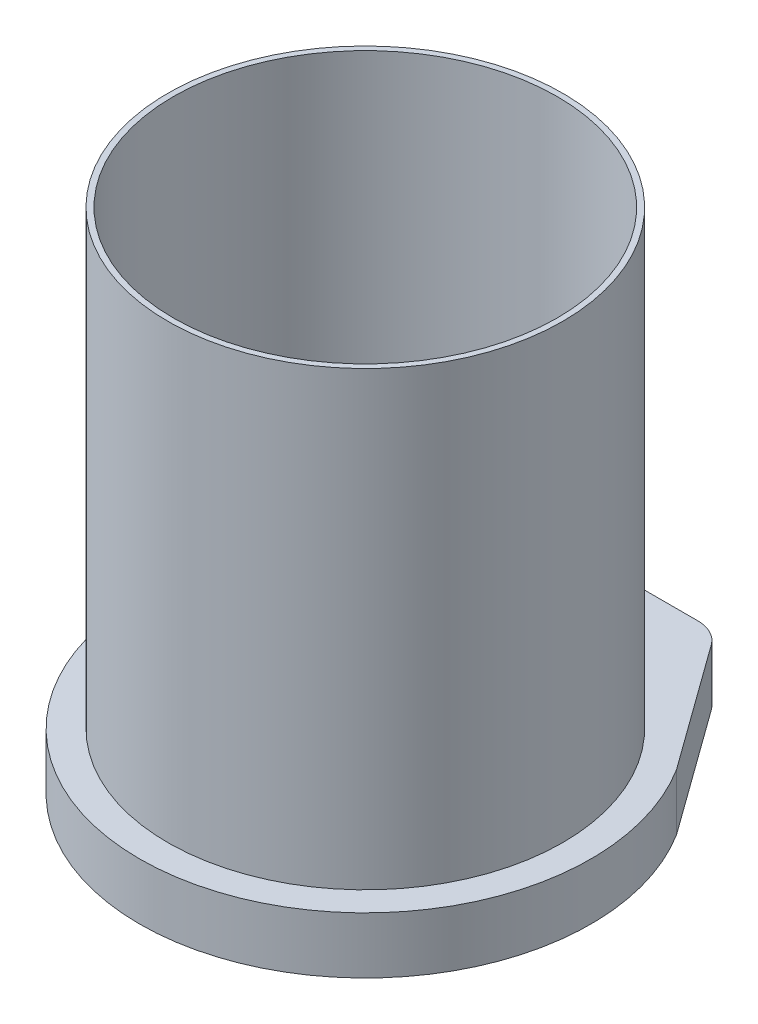
from build123d import *

# Parameters (mm, degrees)
SKETCH_1_R        = 175
SKETCH_1_R_2      = 170
EXTRUDE_1_DEPTH   = 400
EXTRUDE_1_2_DEPTH = 50


with BuildPart() as part:
    # Эскиз1 → Extrude 1 (new body)
    with BuildSketch(Plane(origin=(0, 0, 0), x_dir=(1, 0, 0), z_dir=(0, 1, 0))):
        Circle(SKETCH_1_R)
        Circle(SKETCH_1_R_2, mode=Mode.SUBTRACT)
    extrude(amount=EXTRUDE_1_DEPTH)

    # Эскиз2 → Extrude 1 2 (add)
    with BuildSketch(Plane.XZ):
        with BuildLine():
            Line((-64.674331545, -230), (64.667769704, -230))
            ThreePointArc((64.667769704, -230), (78.320322733, -226.713438487), (88.981545406, -217.573853052))
            Line((88.981545406, -217.573853052), (169.425013579, -106.278712703))
            ThreePointArc((169.425013579, -106.278712703), (-0.414705995, 199.999570047), (-168.982813438, -106.980412985))
            Line((-168.982813438, -106.980412985), (-88.982009615, -217.582286166))
            ThreePointArc((-88.982009615, -217.582286166), (-78.322251075, -226.715806042), (-64.674331545, -230))
        make_face()
    extrude(amount=EXTRUDE_1_2_DEPTH)


solid = part.part
